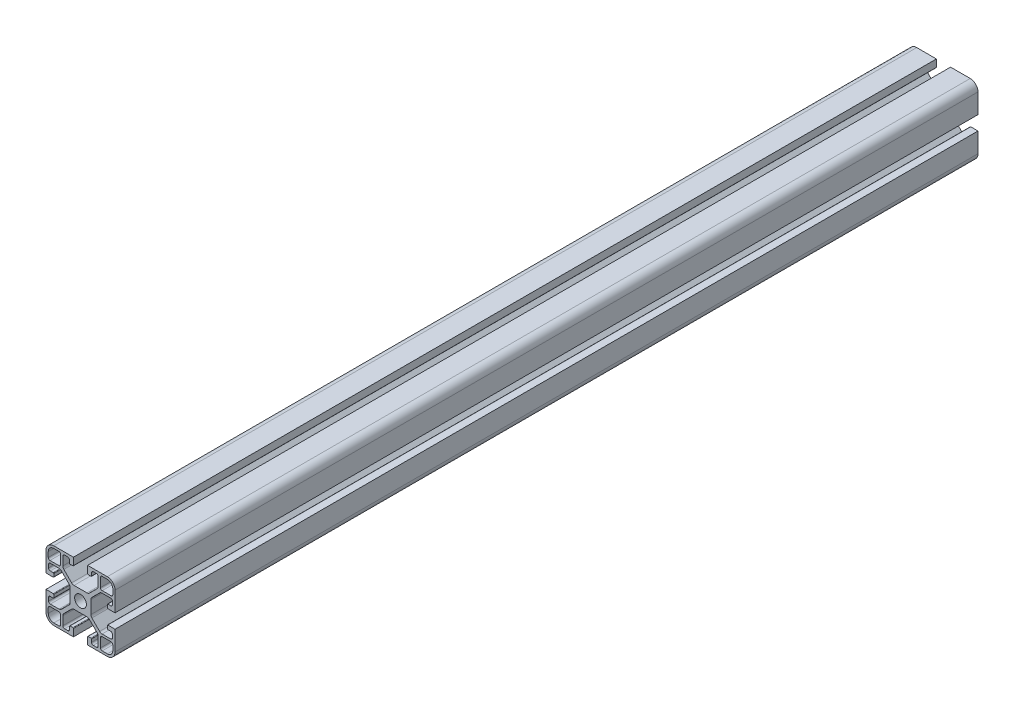
from build123d import *

# Parameters (mm, degrees)
SKETCH1_R           = 3.4
BOSS_EXTRUDE1_DEPTH = 500


with BuildPart() as part:
    # Sketch1 → Boss-Extrude1 (new body)
    with BuildSketch(Plane.XY):
        with BuildLine():
            Line((-20, 4.1), (-20, 15.5))
            ThreePointArc((-20, 15.5), (-18.681980515, 18.681980515), (-15.5, 20))
            Line((-15.5, 20), (-4.1, 20))
            Line((-4.1, 20), (-4.1, 15.8))
            ThreePointArc((-4.1, 15.8), (-4.187867966, 15.587867966), (-4.4, 15.5))
            Line((-4.4, 15.5), (-6.1, 15.5))
            ThreePointArc((-6.1, 15.5), (-6.312132034, 15.587867966), (-6.4, 15.8))
            Line((-6.4, 15.8), (-6.4, 17.5))
            ThreePointArc((-6.4, 17.5), (-6.692893219, 18.207106781), (-7.4, 18.5))
            Line((-7.4, 18.5), (-9.25, 18.5))
            ThreePointArc((-9.25, 18.5), (-9.957106781, 18.207106781), (-10.25, 17.5))
            Line((-10.25, 17.5), (-10.25, 12.492640687))
            ThreePointArc((-10.25, 12.492640687), (-10.097759065, 11.727273822), (-9.664213562, 11.078427125))
            Line((-9.664213562, 11.078427125), (-5.171572875, 6.585786438))
            ThreePointArc((-5.171572875, 6.585786438), (-4.522726178, 6.152240935), (-3.757359313, 6))
            Line((-3.757359313, 6), (3.757359313, 6))
            ThreePointArc((3.757359313, 6), (4.522726178, 6.152240935), (5.171572875, 6.585786438))
            Line((5.171572875, 6.585786438), (9.664213562, 11.078427125))
            ThreePointArc((9.664213562, 11.078427125), (10.097759065, 11.727273822), (10.25, 12.492640687))
            Line((10.25, 12.492640687), (10.25, 17.5))
            ThreePointArc((10.25, 17.5), (9.957106781, 18.207106781), (9.25, 18.5))
            Line((9.25, 18.5), (7.4, 18.5))
            ThreePointArc((7.4, 18.5), (6.692893219, 18.207106781), (6.4, 17.5))
            Line((6.4, 17.5), (6.4, 15.8))
            ThreePointArc((6.4, 15.8), (6.312132034, 15.587867966), (6.1, 15.5))
            Line((6.1, 15.5), (4.4, 15.5))
            ThreePointArc((4.4, 15.5), (4.187867966, 15.587867966), (4.1, 15.8))
            Line((4.1, 15.8), (4.1, 20))
            Line((4.1, 20), (15.5, 20))
            ThreePointArc((15.5, 20), (18.681980515, 18.681980515), (20, 15.5))
            Line((20, 15.5), (20, 4.1))
            Line((20, 4.1), (15.8, 4.1))
            ThreePointArc((15.8, 4.1), (15.587867966, 4.187867966), (15.5, 4.4))
            Line((15.5, 4.4), (15.5, 6.1))
            ThreePointArc((15.5, 6.1), (15.587867966, 6.312132034), (15.8, 6.4))
            Line((15.8, 6.4), (17.5, 6.4))
            ThreePointArc((17.5, 6.4), (18.207106781, 6.692893219), (18.5, 7.4))
            Line((18.5, 7.4), (18.5, 9.25))
            ThreePointArc((18.5, 9.25), (18.207106781, 9.957106781), (17.5, 10.25))
            Line((17.5, 10.25), (12.492640687, 10.25))
            ThreePointArc((12.492640687, 10.25), (11.727273822, 10.097759065), (11.078427125, 9.664213562))
            Line((11.078427125, 9.664213562), (6.585786438, 5.171572875))
            ThreePointArc((6.585786438, 5.171572875), (6.152240935, 4.522726178), (6, 3.757359313))
            Line((6, 3.757359313), (6, -3.757359313))
            ThreePointArc((6, -3.757359313), (6.152240935, -4.522726178), (6.585786438, -5.171572875))
            Line((6.585786438, -5.171572875), (11.078427125, -9.664213562))
            ThreePointArc((11.078427125, -9.664213562), (11.727273822, -10.097759065), (12.492640687, -10.25))
            Line((12.492640687, -10.25), (17.5, -10.25))
            ThreePointArc((17.5, -10.25), (18.207106781, -9.957106781), (18.5, -9.25))
            Line((18.5, -9.25), (18.5, -7.4))
            ThreePointArc((18.5, -7.4), (18.207106781, -6.692893219), (17.5, -6.4))
            Line((17.5, -6.4), (15.8, -6.4))
            ThreePointArc((15.8, -6.4), (15.587867966, -6.312132034), (15.5, -6.1))
            Line((15.5, -6.1), (15.5, -4.4))
            ThreePointArc((15.5, -4.4), (15.587867966, -4.187867966), (15.8, -4.1))
            Line((15.8, -4.1), (20, -4.1))
            Line((20, -4.1), (20, -15.5))
            ThreePointArc((20, -15.5), (18.681980515, -18.681980515), (15.5, -20))
            Line((15.5, -20), (4.1, -20))
            Line((4.1, -20), (4.1, -15.8))
            ThreePointArc((4.1, -15.8), (4.187867966, -15.587867966), (4.4, -15.5))
            Line((4.4, -15.5), (6.1, -15.5))
            ThreePointArc((6.1, -15.5), (6.312132034, -15.587867966), (6.4, -15.8))
            Line((6.4, -15.8), (6.4, -17.5))
            ThreePointArc((6.4, -17.5), (6.692893219, -18.207106781), (7.4, -18.5))
            Line((7.4, -18.5), (9.25, -18.5))
            ThreePointArc((9.25, -18.5), (9.957106781, -18.207106781), (10.25, -17.5))
            Line((10.25, -17.5), (10.25, -12.492640687))
            ThreePointArc((10.25, -12.492640687), (10.097759065, -11.727273822), (9.664213562, -11.078427125))
            Line((9.664213562, -11.078427125), (5.171572875, -6.585786438))
            ThreePointArc((5.171572875, -6.585786438), (4.522726178, -6.152240935), (3.757359313, -6))
            Line((3.757359313, -6), (-3.757359313, -6))
            ThreePointArc((-3.757359313, -6), (-4.522726178, -6.152240935), (-5.171572875, -6.585786438))
            Line((-5.171572875, -6.585786438), (-9.664213562, -11.078427125))
            ThreePointArc((-9.664213562, -11.078427125), (-10.097759065, -11.727273822), (-10.25, -12.492640687))
            Line((-10.25, -12.492640687), (-10.25, -17.5))
            ThreePointArc((-10.25, -17.5), (-9.957106781, -18.207106781), (-9.25, -18.5))
            Line((-9.25, -18.5), (-7.4, -18.5))
            ThreePointArc((-7.4, -18.5), (-6.692893219, -18.207106781), (-6.4, -17.5))
            Line((-6.4, -17.5), (-6.4, -15.8))
            ThreePointArc((-6.4, -15.8), (-6.312132034, -15.587867966), (-6.1, -15.5))
            Line((-6.1, -15.5), (-4.4, -15.5))
            ThreePointArc((-4.4, -15.5), (-4.187867966, -15.587867966), (-4.1, -15.8))
            Line((-4.1, -15.8), (-4.1, -20))
            Line((-4.1, -20), (-15.5, -20))
            ThreePointArc((-15.5, -20), (-18.681980515, -18.681980515), (-20, -15.5))
            Line((-20, -15.5), (-20, -4.1))
            Line((-20, -4.1), (-15.8, -4.1))
            ThreePointArc((-15.8, -4.1), (-15.587867966, -4.187867966), (-15.5, -4.4))
            Line((-15.5, -4.4), (-15.5, -6.1))
            ThreePointArc((-15.5, -6.1), (-15.587867966, -6.312132034), (-15.8, -6.4))
            Line((-15.8, -6.4), (-17.5, -6.4))
            ThreePointArc((-17.5, -6.4), (-18.207106781, -6.692893219), (-18.5, -7.4))
            Line((-18.5, -7.4), (-18.5, -9.25))
            ThreePointArc((-18.5, -9.25), (-18.207106781, -9.957106781), (-17.5, -10.25))
            Line((-17.5, -10.25), (-12.492640687, -10.25))
            ThreePointArc((-12.492640687, -10.25), (-11.727273822, -10.097759065), (-11.078427125, -9.664213562))
            Line((-11.078427125, -9.664213562), (-6.585786438, -5.171572875))
            ThreePointArc((-6.585786438, -5.171572875), (-6.152240935, -4.522726178), (-6, -3.757359313))
            Line((-6, -3.757359313), (-6, 3.757359313))
            ThreePointArc((-6, 3.757359313), (-6.152240935, 4.522726178), (-6.585786438, 5.171572875))
            Line((-6.585786438, 5.171572875), (-11.078427125, 9.664213562))
            ThreePointArc((-11.078427125, 9.664213562), (-11.727273822, 10.097759065), (-12.492640687, 10.25))
            Line((-12.492640687, 10.25), (-17.5, 10.25))
            ThreePointArc((-17.5, 10.25), (-18.207106781, 9.957106781), (-18.5, 9.25))
            Line((-18.5, 9.25), (-18.5, 7.4))
            ThreePointArc((-18.5, 7.4), (-18.207106781, 6.692893219), (-17.5, 6.4))
            Line((-17.5, 6.4), (-15.8, 6.4))
            ThreePointArc((-15.8, 6.4), (-15.587867966, 6.312132034), (-15.5, 6.1))
            Line((-15.5, 6.1), (-15.5, 4.4))
            ThreePointArc((-15.5, 4.4), (-15.587867966, 4.187867966), (-15.8, 4.1))
            Line((-15.8, 4.1), (-20, 4.1))
        make_face()
        Circle(SKETCH1_R, mode=Mode.SUBTRACT)
        with BuildLine():
            Line((18.7, 12.55), (18.7, 15.5))
            ThreePointArc((18.7, 15.5), (17.7627417, 17.7627417), (15.5, 18.7))
            Line((15.5, 18.7), (12.55, 18.7))
            ThreePointArc((12.55, 18.7), (11.842893219, 18.407106781), (11.55, 17.7))
            Line((11.55, 17.7), (11.55, 12.55))
            ThreePointArc((11.55, 12.55), (11.842893219, 11.842893219), (12.55, 11.55))
            Line((12.55, 11.55), (17.7, 11.55))
            ThreePointArc((17.7, 11.55), (18.407106781, 11.842893219), (18.7, 12.55))
        make_face(mode=Mode.SUBTRACT)
        with BuildLine():
            Line((-18.7, -12.55), (-18.7, -15.5))
            ThreePointArc((-18.7, -15.5), (-17.7627417, -17.7627417), (-15.5, -18.7))
            Line((-15.5, -18.7), (-12.55, -18.7))
            ThreePointArc((-12.55, -18.7), (-11.842893219, -18.407106781), (-11.55, -17.7))
            Line((-11.55, -17.7), (-11.55, -12.55))
            ThreePointArc((-11.55, -12.55), (-11.842893219, -11.842893219), (-12.55, -11.55))
            Line((-12.55, -11.55), (-17.7, -11.55))
            ThreePointArc((-17.7, -11.55), (-18.407106781, -11.842893219), (-18.7, -12.55))
        make_face(mode=Mode.SUBTRACT)
        with BuildLine():
            Line((-12.55, 18.7), (-15.5, 18.7))
            ThreePointArc((-15.5, 18.7), (-17.7627417, 17.7627417), (-18.7, 15.5))
            Line((-18.7, 15.5), (-18.7, 12.55))
            ThreePointArc((-18.7, 12.55), (-18.407106781, 11.842893219), (-17.7, 11.55))
            Line((-17.7, 11.55), (-12.55, 11.55))
            ThreePointArc((-12.55, 11.55), (-11.842893219, 11.842893219), (-11.55, 12.55))
            Line((-11.55, 12.55), (-11.55, 17.7))
            ThreePointArc((-11.55, 17.7), (-11.842893219, 18.407106781), (-12.55, 18.7))
        make_face(mode=Mode.SUBTRACT)
        with BuildLine():
            Line((12.55, -18.7), (15.5, -18.7))
            ThreePointArc((15.5, -18.7), (17.7627417, -17.7627417), (18.7, -15.5))
            Line((18.7, -15.5), (18.7, -12.55))
            ThreePointArc((18.7, -12.55), (18.407106781, -11.842893219), (17.7, -11.55))
            Line((17.7, -11.55), (12.55, -11.55))
            ThreePointArc((12.55, -11.55), (11.842893219, -11.842893219), (11.55, -12.55))
            Line((11.55, -12.55), (11.55, -17.7))
            ThreePointArc((11.55, -17.7), (11.842893219, -18.407106781), (12.55, -18.7))
        make_face(mode=Mode.SUBTRACT)
    extrude(amount=BOSS_EXTRUDE1_DEPTH)


solid = part.part
